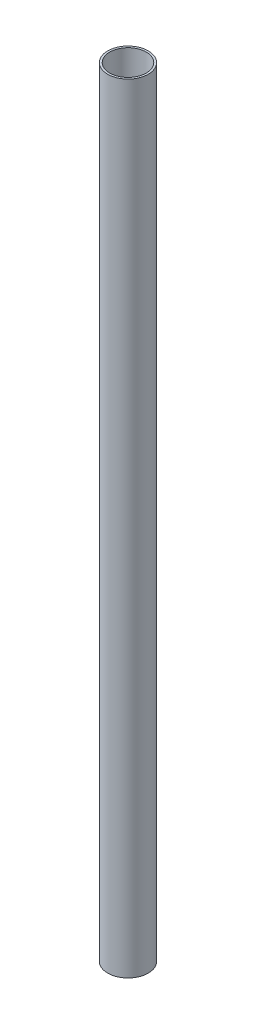
from build123d import *

# Parameters (mm, degrees)
SKETCH1_R           = 15.875
SKETCH1_R_2         = 14.2875
BOSS_EXTRUDE1_DEPTH = 304.8


with BuildPart() as part:
    # Sketch1 → Boss-Extrude1 (new body, symmetric)
    with BuildSketch(Plane(origin=(0, 0, 0), x_dir=(1, 0, 0), z_dir=(0, 1, 0))):
        Circle(SKETCH1_R)
        Circle(SKETCH1_R_2, mode=Mode.SUBTRACT)
    extrude(amount=BOSS_EXTRUDE1_DEPTH, both=True)


solid = part.part
